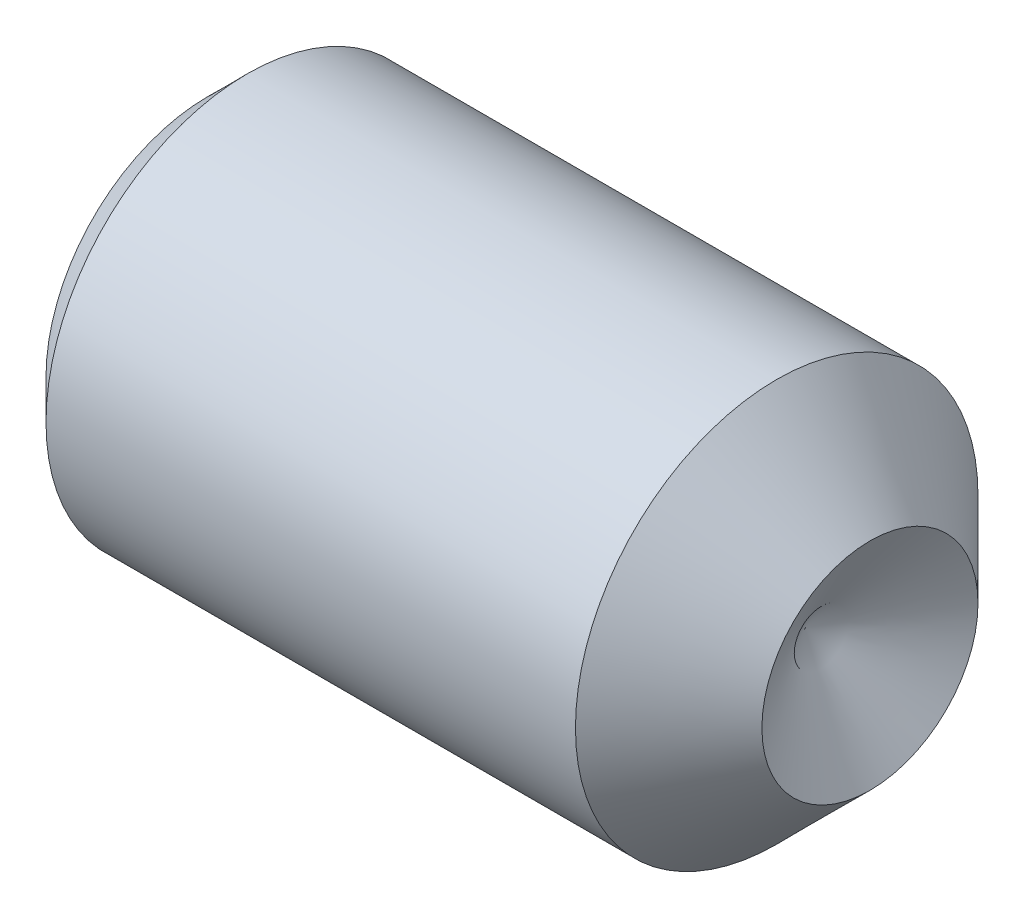
from build123d import *

# Parameters (mm, degrees)
HEX_2_DEPTH = 2.54


with BuildPart() as part:
    # BodySke → BaseBody (revolve)
    with BuildSketch(Plane.XY):
        Polygon((0, 0), (0, 1.94056), (0.47244, 2.413), (6.8199, 2.413), (7.9375, 1.2954), (7.159145154, 0), align=None)
    revolve(axis=Axis((-12.7, 0, 0), (1, 0, 0)))

    # Sketch2 → Hex 2 (cut)
    with BuildSketch(Plane.ZY):
        Polygon((0.687041047, 1.18999), (-0.687041047, 1.18999), (-1.374082094, 0), (-0.687041047, -1.18999), (0.687041047, -1.18999), (1.374082094, 0), align=None)
    extrude(amount=-HEX_2_DEPTH, mode=Mode.SUBTRACT)


solid = part.part
